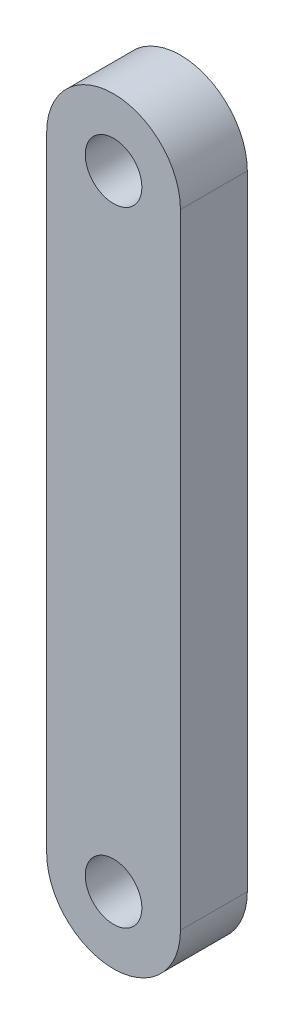
from build123d import *

# Parameters (mm, degrees)
SKETCH1_R           = 3.175
BOSS_EXTRUDE1_DEPTH = 7.5


with BuildPart() as part:
    # Sketch1 → Boss-Extrude1 (new body)
    with BuildSketch(Plane.XY):
        with BuildLine():
            Line((-7.5, 70), (-7.5, 0))
            ThreePointArc((-7.5, 0), (0, -7.5), (7.5, 0))
            Line((7.5, 0), (7.5, 70))
            ThreePointArc((7.5, 70), (0, 77.5), (-7.5, 70))
        make_face()
        with Locations((0, 70)):
            Circle(SKETCH1_R, mode=Mode.SUBTRACT)
        Circle(SKETCH1_R, mode=Mode.SUBTRACT)
    extrude(amount=BOSS_EXTRUDE1_DEPTH)


solid = part.part
